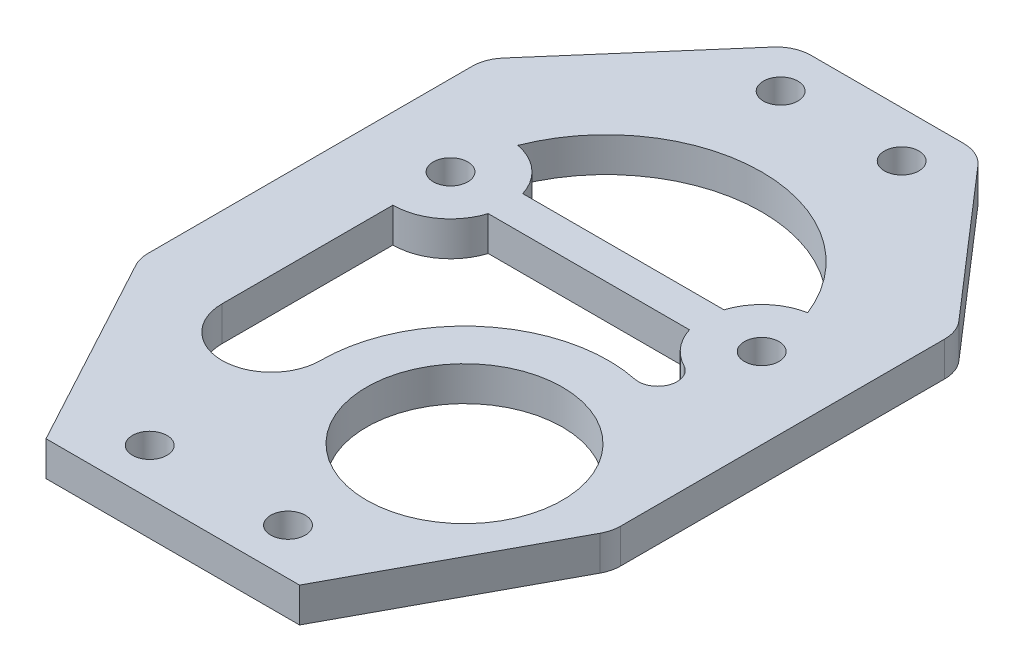
from build123d import *

# Parameters (mm, degrees)
SKETCH1_R           = 1.5
SKETCH1_R_2         = 8.5
BOSS_EXTRUDE1_DEPTH = 1.5
FILLET1_R           = 3


with BuildPart() as part:
    # Sketch1 → Boss-Extrude1 (new body, symmetric)
    with BuildSketch(Plane(origin=(0, 0, 0), x_dir=(1, 0, 0), z_dir=(0, 1, 0))):
        Polygon((8, 24.400284093), (-8, 24.400284093), (-20.5, 10), (-20.5, -20), (-11, -37.599715907), (11, -37.599715907), (20.5, -20), (20.5, 10), align=None)
        with Locations((-5.25, 20.39454584)):
            Circle(SKETCH1_R, mode=Mode.SUBTRACT)
        with Locations((-6, -33.599715907)):
            Circle(SKETCH1_R, mode=Mode.SUBTRACT)
        with Locations((6, -33.599715907)):
            Circle(SKETCH1_R, mode=Mode.SUBTRACT)
        with Locations((5.25, 20.39454584)):
            Circle(SKETCH1_R, mode=Mode.SUBTRACT)
        with Locations((-13.5, 0)):
            Circle(SKETCH1_R, mode=Mode.SUBTRACT)
        with Locations((13.5, 0)):
            Circle(SKETCH1_R, mode=Mode.SUBTRACT)
        with Locations((7.530163354, -19.817414772)):
            Circle(SKETCH1_R_2, mode=Mode.SUBTRACT)
        with BuildLine():
            Line((-13.5, -5), (-13.5, -19.817414772))
            ThreePointArc((-13.5, -19.817414772), (-9.234918323, -24.082496449), (-4.969836646, -19.817414772))
            ThreePointArc((-4.969836646, -19.817414772), (-0.361028795, -10.12313365), (10.06681719, -7.57750516))
            ThreePointArc((10.06681719, -7.57750516), (11.99598649, -6.493442694), (11.187975781, -4.433344563))
            ThreePointArc((11.187975781, -4.433344563), (9.667400631, -3.211102938), (8.730303993, -1.5))
            Line((8.730303993, -1.5), (-8.730303993, -1.5))
            ThreePointArc((-8.730303993, -1.5), (-10.541960108, -4.031128874), (-13.5, -5))
        make_face(mode=Mode.SUBTRACT)
        with BuildLine():
            Line((8.730303993, 1.5), (-8.730303993, 1.5))
            ThreePointArc((-8.730303993, 1.5), (-10.179901517, 3.738575405), (-12.574074074, 4.913518208))
            ThreePointArc((-12.574074074, 4.913518208), (0, 13.5), (12.574074074, 4.913518208))
            ThreePointArc((12.574074074, 4.913518208), (10.179901517, 3.738575405), (8.730303993, 1.5))
        make_face(mode=Mode.SUBTRACT)
    extrude(amount=BOSS_EXTRUDE1_DEPTH, both=True)

    # Fillet1
    fillet1_edges = [part.edges().sort_by_distance(p)[0] for p in [
        (-20.5, 0, 20),
        (-20.5, 0, -10),
        (-8, 0, -24.400284093),
        (8, 0, -24.400284093),
        (20.5, 0, -10),
        (20.5, 0, 20),
    ]]
    fillet(fillet1_edges, radius=FILLET1_R)


solid = part.part
